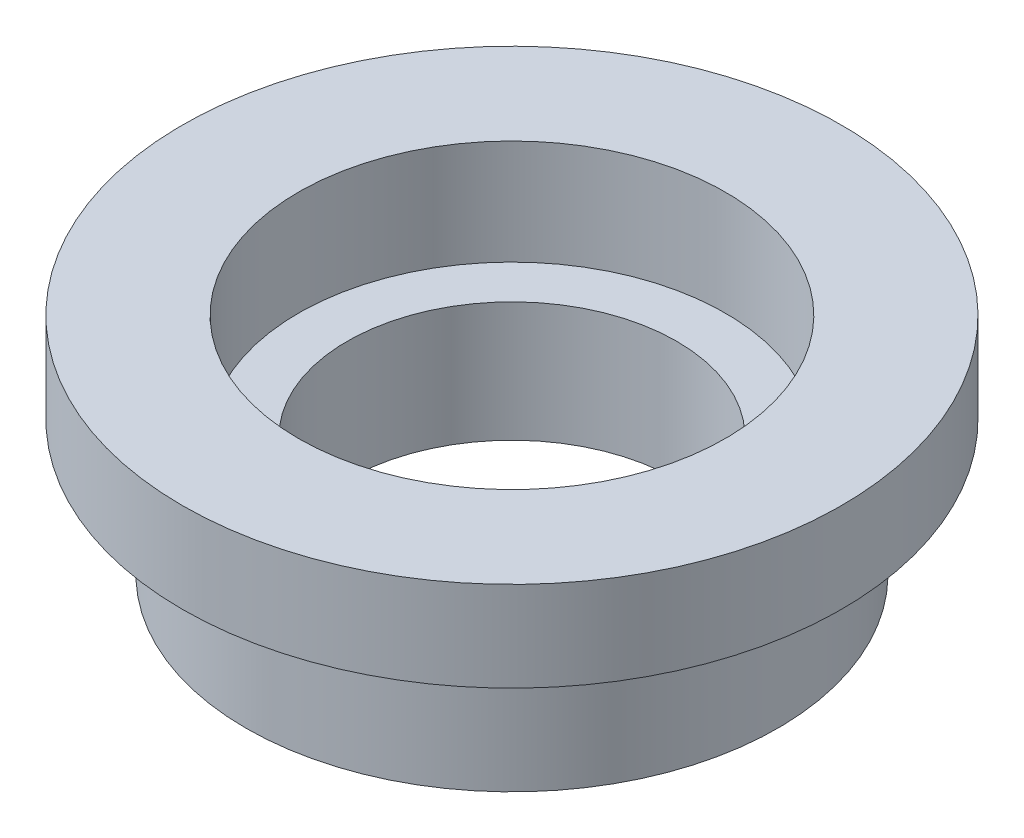
from build123d import *

# Parameters (mm, degrees)
SKETCH1_R           = 8.875
SKETCH1_R_2         = 5.5
BOSS_EXTRUDE1_DEPTH = 2
SKETCH2_R           = 9
SKETCH2_R_2         = 7.125
BOSS_EXTRUDE2_DEPTH = 3.5
SKETCH3_R           = 11
SKETCH3_R_2         = 9
BOSS_EXTRUDE3_DEPTH = 3


with BuildPart() as part:
    # Sketch1 → Boss-Extrude1 (new body, symmetric)
    with BuildSketch(Plane(origin=(0, 0, 0), x_dir=(1, 0, 0), z_dir=(0, 1, 0))):
        Circle(SKETCH1_R)
        Circle(SKETCH1_R_2, mode=Mode.SUBTRACT)
    extrude(amount=BOSS_EXTRUDE1_DEPTH, both=True)

    # Sketch2 → Boss-Extrude2 (add)
    with BuildSketch(Plane(origin=(0, 2, 0), x_dir=(1, 0, 0), z_dir=(0, 1, 0))):
        Circle(SKETCH2_R)
        Circle(SKETCH2_R_2, mode=Mode.SUBTRACT)
    extrude(amount=BOSS_EXTRUDE2_DEPTH)

    # Sketch3 → Boss-Extrude3 (add)
    with BuildSketch(Plane(origin=(0, 5.5, 0), x_dir=(1, 0, 0), z_dir=(0, 1, 0))):
        Circle(SKETCH3_R)
        Circle(SKETCH3_R_2, mode=Mode.SUBTRACT)
    extrude(amount=-BOSS_EXTRUDE3_DEPTH)


solid = part.part
